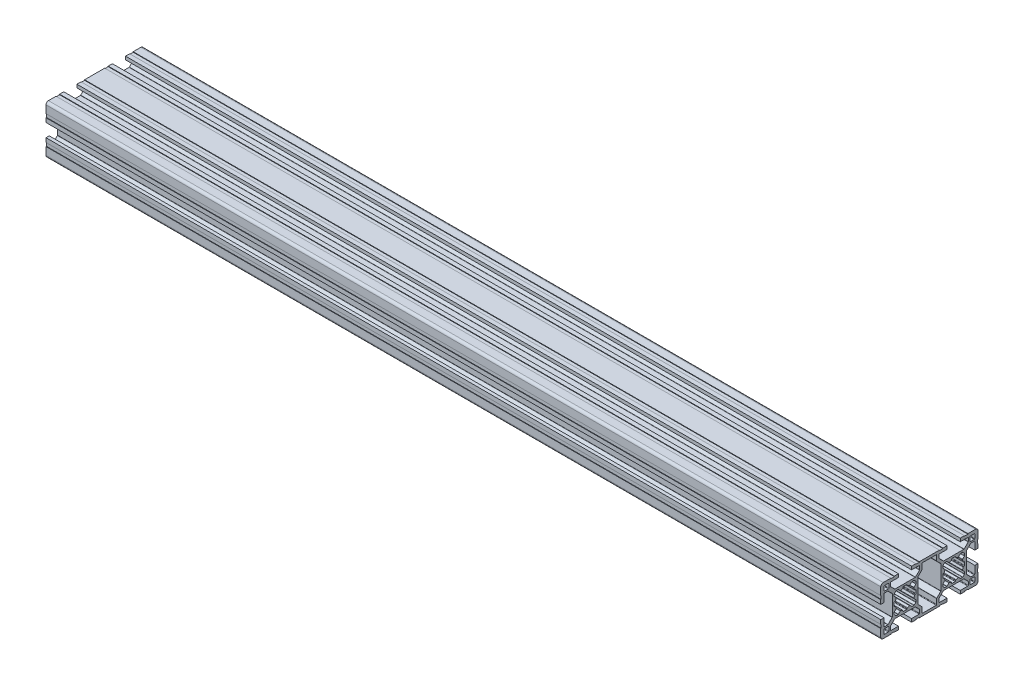
from build123d import *

# Parameters (mm, degrees)
RETANGULAR_PF30_02_PERFIL_3060_B_SICO_DEPTH = 515


with BuildPart() as part:
    # Sketch11 → Retangular PF30-02 - PERFIL 3060 BÁSICO(1) (new body)
    with BuildSketch(Plane.YZ.offset(-257.5)):
        with BuildLine():
            Line((-10.467761979, 23.914900409), (-7.987862303, 21.435000909))
            ThreePointArc((-7.987862303, 21.435000909), (-7.922830472, 21.337673902), (-7.89999433, 21.222868867))
            Line((-7.89999433, 21.222868867), (-7.89999433, 8.78267257))
            ThreePointArc((-7.89999433, 8.78267257), (-7.922830472, 8.667867535), (-7.987862303, 8.570540528))
            Line((-7.987862303, 8.570540528), (-10.467761979, 6.090641028))
            ThreePointArc((-10.467761979, 6.090641028), (-10.565088981, 6.025609208), (-10.679894006, 6.00277307))
            Line((-10.679894006, 6.00277307), (-12.699995366, 6.00277307))
            ThreePointArc((-12.699995366, 6.00277307), (-12.9121274, 6.090641035), (-12.999995366, 6.30277307))
            Line((-12.999995366, 6.30277307), (-12.999995366, 10.952772018))
            Line((-12.999995366, 10.952772018), (-14.999995923, 10.952772018))
            Line((-14.999995923, 10.952772018), (-14.999995923, 8.402773901))
            Line((-14.999995923, 8.402773901), (-14.699995922, 8.402773901))
            Line((-14.699995922, 8.402773901), (-14.699995922, 6.2027739))
            Line((-14.699995922, 6.2027739), (-14.999995923, 6.2027739))
            Line((-14.999995923, 6.2027739), (-14.999995923, -6.197224309))
            Line((-14.999995923, -6.197224309), (-14.699995922, -6.197224309))
            Line((-14.699995922, -6.197224309), (-14.699995922, -8.397224309))
            Line((-14.699995922, -8.397224309), (-14.999995923, -8.397224309))
            Line((-14.999995923, -8.397224309), (-14.999995923, -10.947222427))
            Line((-14.999995923, -10.947222427), (-12.999995366, -10.947222427))
            Line((-12.999995366, -10.947222427), (-12.999995366, -6.297223478))
            ThreePointArc((-12.999995366, -6.297223478), (-12.9121274, -6.085091444), (-12.699995366, -5.997223478))
            Line((-12.699995366, -5.997223478), (-10.679894006, -5.997223478))
            ThreePointArc((-10.679894006, -5.997223478), (-10.565088981, -6.020059616), (-10.467761979, -6.085091436))
            Line((-10.467761979, -6.085091436), (-7.987862303, -8.564990936))
            ThreePointArc((-7.987862303, -8.564990936), (-7.922830472, -8.662317943), (-7.89999433, -8.777122978))
            Line((-7.89999433, -8.777122978), (-7.89999433, -21.217319276))
            ThreePointArc((-7.89999433, -21.217319276), (-7.922830472, -21.33212431), (-7.987862303, -21.429451318))
            Line((-7.987862303, -21.429451318), (-10.467761979, -23.909350818))
            ThreePointArc((-10.467761979, -23.909350818), (-10.565088981, -23.974382637), (-10.679894006, -23.997218776))
            Line((-10.679894006, -23.997218776), (-12.699995366, -23.997218776))
            ThreePointArc((-12.699995366, -23.997218776), (-12.9121274, -23.90935081), (-12.999995366, -23.697218776))
            Line((-12.999995366, -23.697218776), (-12.999995366, -19.047219827))
            Line((-12.999995366, -19.047219827), (-14.999995923, -19.047219827))
            Line((-14.999995923, -19.047219827), (-14.999995923, -21.597217945))
            Line((-14.999995923, -21.597217945), (-14.699995922, -21.597217945))
            Line((-14.699995922, -21.597217945), (-14.699995922, -23.797217945))
            Line((-14.699995922, -23.797217945), (-14.999995923, -23.797217945))
            Line((-14.999995923, -23.797217945), (-14.999995923, -28.497216952))
            ThreePointArc((-14.999995923, -28.497216952), (-14.560656066, -29.557877193), (-13.499995825, -29.997217049))
            Line((-13.499995825, -29.997217049), (-8.799996802, -29.997217049))
            Line((-8.799996802, -29.997217049), (-8.799996802, -29.697217049))
            Line((-8.799996802, -29.697217049), (-6.599996802, -29.697217049))
            Line((-6.599996802, -29.697217049), (-6.599996802, -29.99721705))
            Line((-6.599996802, -29.99721705), (-4.0499987, -29.99721705))
            Line((-4.0499987, -29.99721705), (-4.0499987, -27.997216493))
            Line((-4.0499987, -27.997216493), (-8.699997649, -27.997216493))
            ThreePointArc((-8.699997649, -27.997216493), (-8.912129683, -27.909348527), (-8.999997649, -27.697216493))
            Line((-8.999997649, -27.697216493), (-8.999997649, -25.677115133))
            ThreePointArc((-8.999997649, -25.677115133), (-8.977161511, -25.562310108), (-8.912129691, -25.464983106))
            Line((-8.912129691, -25.464983106), (-6.432230191, -22.98508343))
            ThreePointArc((-6.432230191, -22.98508343), (-6.334903184, -22.920051599), (-6.220098149, -22.897215457))
            Line((-6.220098149, -22.897215457), (6.220098149, -22.897215457))
            ThreePointArc((6.220098149, -22.897215457), (6.334903184, -22.920051599), (6.432230191, -22.98508343))
            Line((6.432230191, -22.98508343), (8.912129691, -25.464983106))
            ThreePointArc((8.912129691, -25.464983106), (8.977161511, -25.562310108), (8.999997649, -25.677115133))
            Line((8.999997649, -25.677115133), (8.999997649, -27.697216493))
            ThreePointArc((8.999997649, -27.697216493), (8.912129683, -27.909348527), (8.699997649, -27.997216493))
            Line((8.699997649, -27.997216493), (4.0499987, -27.997216493))
            Line((4.0499987, -27.997216493), (4.0499987, -29.99721705))
            Line((4.0499987, -29.99721705), (6.599996802, -29.99721705))
            Line((6.599996802, -29.99721705), (6.599996802, -29.697217049))
            Line((6.599996802, -29.697217049), (8.799996802, -29.697217049))
            Line((8.799996802, -29.697217049), (8.799996802, -29.997217049))
            Line((8.799996802, -29.997217049), (13.499995825, -29.997217049))
            ThreePointArc((13.499995825, -29.997217049), (14.560656066, -29.557877193), (14.999995923, -28.497216952))
            Line((14.999995923, -28.497216952), (14.999995923, -23.797217945))
            Line((14.999995923, -23.797217945), (14.699995922, -23.797217945))
            Line((14.699995922, -23.797217945), (14.699995922, -21.597217945))
            Line((14.699995922, -21.597217945), (14.999995923, -21.597217945))
            Line((14.999995923, -21.597217945), (14.999995923, -19.047219827))
            Line((14.999995923, -19.047219827), (12.999995366, -19.047219827))
            Line((12.999995366, -19.047219827), (12.999995366, -23.697218776))
            ThreePointArc((12.999995366, -23.697218776), (12.9121274, -23.90935081), (12.699995366, -23.997218776))
            Line((12.699995366, -23.997218776), (10.679894006, -23.997218776))
            ThreePointArc((10.679894006, -23.997218776), (10.565088981, -23.974382637), (10.467761979, -23.909350818))
            Line((10.467761979, -23.909350818), (7.987862303, -21.429451318))
            ThreePointArc((7.987862303, -21.429451318), (7.922830472, -21.33212431), (7.89999433, -21.217319276))
            Line((7.89999433, -21.217319276), (7.89999433, -8.777122978))
            ThreePointArc((7.89999433, -8.777122978), (7.922830472, -8.662317943), (7.987862303, -8.564990936))
            Line((7.987862303, -8.564990936), (10.467761979, -6.085091436))
            ThreePointArc((10.467761979, -6.085091436), (10.565088981, -6.020059616), (10.679894006, -5.997223478))
            Line((10.679894006, -5.997223478), (12.699995366, -5.997223478))
            ThreePointArc((12.699995366, -5.997223478), (12.9121274, -6.085091444), (12.999995366, -6.297223478))
            Line((12.999995366, -6.297223478), (12.999995366, -10.947222427))
            Line((12.999995366, -10.947222427), (14.999995923, -10.947222427))
            Line((14.999995923, -10.947222427), (14.999995923, -8.397224309))
            Line((14.999995923, -8.397224309), (14.699995922, -8.397224309))
            Line((14.699995922, -8.397224309), (14.699995922, -6.197224309))
            Line((14.699995922, -6.197224309), (14.999995923, -6.197224309))
            Line((14.999995923, -6.197224309), (14.999995923, 6.2027739))
            Line((14.999995923, 6.2027739), (14.699995922, 6.2027739))
            Line((14.699995922, 6.2027739), (14.699995922, 8.402773901))
            Line((14.699995922, 8.402773901), (14.999995923, 8.402773901))
            Line((14.999995923, 8.402773901), (14.999995923, 10.952772018))
            Line((14.999995923, 10.952772018), (12.999995366, 10.952772018))
            Line((12.999995366, 10.952772018), (12.999995366, 6.30277307))
            ThreePointArc((12.999995366, 6.30277307), (12.9121274, 6.090641035), (12.699995366, 6.00277307))
            Line((12.699995366, 6.00277307), (10.679894006, 6.00277307))
            ThreePointArc((10.679894006, 6.00277307), (10.565088981, 6.025609208), (10.467761979, 6.090641028))
            Line((10.467761979, 6.090641028), (7.987862303, 8.570540528))
            ThreePointArc((7.987862303, 8.570540528), (7.922830472, 8.667867535), (7.89999433, 8.78267257))
            Line((7.89999433, 8.78267257), (7.89999433, 21.222868867))
            ThreePointArc((7.89999433, 21.222868867), (7.922830472, 21.337673902), (7.987862303, 21.435000909))
            Line((7.987862303, 21.435000909), (10.467761979, 23.914900409))
            ThreePointArc((10.467761979, 23.914900409), (10.565088981, 23.979932229), (10.679894006, 24.002768367))
            Line((10.679894006, 24.002768367), (12.699995366, 24.002768367))
            ThreePointArc((12.699995366, 24.002768367), (12.9121274, 23.914900401), (12.999995366, 23.702768367))
            Line((12.999995366, 23.702768367), (12.999995366, 19.052769418))
            Line((12.999995366, 19.052769418), (14.999995923, 19.052769418))
            Line((14.999995923, 19.052769418), (14.999995923, 21.602767536))
            Line((14.999995923, 21.602767536), (14.699995922, 21.602767536))
            Line((14.699995922, 21.602767536), (14.699995922, 23.802767536))
            Line((14.699995922, 23.802767536), (14.999995923, 23.802767536))
            Line((14.999995923, 23.802767536), (14.999995923, 28.502766544))
            ThreePointArc((14.999995923, 28.502766544), (14.560656066, 29.563426784), (13.499995825, 30.002766641))
            Line((13.499995825, 30.002766641), (8.799996802, 30.002766641))
            Line((8.799996802, 30.002766641), (8.799996802, 29.702766641))
            Line((8.799996802, 29.702766641), (6.599996802, 29.702766641))
            Line((6.599996802, 29.702766641), (6.599996802, 30.002766641))
            Line((6.599996802, 30.002766641), (4.0499987, 30.002766641))
            Line((4.0499987, 30.002766641), (4.0499987, 28.002766084))
            Line((4.0499987, 28.002766084), (8.699997649, 28.002766084))
            ThreePointArc((8.699997649, 28.002766084), (8.912129683, 27.914898119), (8.999997649, 27.702766084))
            Line((8.999997649, 27.702766084), (8.999997649, 25.682664725))
            ThreePointArc((8.999997649, 25.682664725), (8.977161511, 25.5678597), (8.912129691, 25.470532698))
            Line((8.912129691, 25.470532698), (6.432230191, 22.990633021))
            ThreePointArc((6.432230191, 22.990633021), (6.334903184, 22.92560119), (6.220098149, 22.902765048))
            Line((6.220098149, 22.902765048), (-6.220098149, 22.902765048))
            ThreePointArc((-6.220098149, 22.902765048), (-6.334903184, 22.92560119), (-6.432230191, 22.990633021))
            Line((-6.432230191, 22.990633021), (-8.912129691, 25.470532698))
            ThreePointArc((-8.912129691, 25.470532698), (-8.977161511, 25.5678597), (-8.999997649, 25.682664725))
            Line((-8.999997649, 25.682664725), (-8.999997649, 27.702766084))
            ThreePointArc((-8.999997649, 27.702766084), (-8.912129683, 27.914898119), (-8.699997649, 28.002766084))
            Line((-8.699997649, 28.002766084), (-4.0499987, 28.002766084))
            Line((-4.0499987, 28.002766084), (-4.0499987, 30.002766641))
            Line((-4.0499987, 30.002766641), (-6.599996802, 30.002766641))
            Line((-6.599996802, 30.002766641), (-6.599996802, 29.702766641))
            Line((-6.599996802, 29.702766641), (-8.799996802, 29.702766641))
            Line((-8.799996802, 29.702766641), (-8.799996802, 30.002766641))
            Line((-8.799996802, 30.002766641), (-13.499995825, 30.002766641))
            ThreePointArc((-13.499995825, 30.002766641), (-14.560656066, 29.563426784), (-14.999995923, 28.502766544))
            Line((-14.999995923, 28.502766544), (-14.999995923, 23.802767536))
            Line((-14.999995923, 23.802767536), (-14.699995922, 23.802767536))
            Line((-14.699995922, 23.802767536), (-14.699995922, 21.602767536))
            Line((-14.699995922, 21.602767536), (-14.999995923, 21.602767536))
            Line((-14.999995923, 21.602767536), (-14.999995923, 19.052769418))
            Line((-14.999995923, 19.052769418), (-12.999995366, 19.052769418))
            Line((-12.999995366, 19.052769418), (-12.999995366, 23.702768367))
            ThreePointArc((-12.999995366, 23.702768367), (-12.9121274, 23.914900401), (-12.699995366, 24.002768367))
            Line((-12.699995366, 24.002768367), (-10.679894006, 24.002768367))
            ThreePointArc((-10.679894006, 24.002768367), (-10.565088981, 23.979932229), (-10.467761979, 23.914900409))
        make_face()
        with BuildLine():
            Line((-9.846446918, -4.590642769), (-7.422182, -7.014907859))
            ThreePointArc((-7.422182, -7.014907859), (-7.324854993, -7.07993969), (-7.210049959, -7.102775832))
            Line((-7.210049959, -7.102775832), (7.210049959, -7.102775832))
            ThreePointArc((7.210049959, -7.102775832), (7.324854993, -7.07993969), (7.422182, -7.014907859))
            Line((7.422182, -7.014907859), (9.846446918, -4.590642769))
            ThreePointArc((9.846446918, -4.590642769), (9.943773925, -4.525610938), (10.05857896, -4.502774796))
            Line((10.05857896, -4.502774796), (13.2, -4.502774796))
            ThreePointArc((13.2, -4.502774796), (13.412132034, -4.41490683), (13.5, -4.202774796))
            Line((13.5, -4.202774796), (13.5, 4.197225204))
            ThreePointArc((13.5, 4.197225204), (13.412132034, 4.409357239), (13.2, 4.497225204))
            Line((13.2, 4.497225204), (10.05857896, 4.497225204))
            ThreePointArc((10.05857896, 4.497225204), (9.943773925, 4.520061347), (9.846446918, 4.585093178))
            Line((9.846446918, 4.585093178), (7.422182001, 7.009358267))
            ThreePointArc((7.422182001, 7.009358267), (7.324854993, 7.074390098), (7.210049959, 7.097226241))
            Line((7.210049959, 7.097226241), (-7.210049958, 7.097226241))
            ThreePointArc((-7.210049958, 7.097226241), (-7.324854993, 7.074390098), (-7.422182, 7.009358267))
            Line((-7.422182, 7.009358267), (-9.846446917, 4.585093178))
            ThreePointArc((-9.846446917, 4.585093178), (-9.943773925, 4.520061347), (-10.058578959, 4.497225204))
            Line((-10.058578959, 4.497225204), (-13.2, 4.497225204))
            ThreePointArc((-13.2, 4.497225204), (-13.412132034, 4.409357239), (-13.5, 4.197225204))
            Line((-13.5, 4.197225204), (-13.5, -4.202774796))
            ThreePointArc((-13.5, -4.202774796), (-13.412132034, -4.41490683), (-13.2, -4.502774796))
            Line((-13.2, -4.502774796), (-10.05857896, -4.502774796))
            ThreePointArc((-10.05857896, -4.502774796), (-9.943773925, -4.525610938), (-9.846446918, -4.590642769))
        make_face(mode=Mode.SUBTRACT)
        with BuildLine():
            Line((-6.69999433, 15.952769357), (-6.69999433, 14.05277208))
            ThreePointArc((-6.69999433, 14.05277208), (-6.612125883, 13.840639564), (-6.399992969, 13.75277208))
            Line((-6.399992969, 13.75277208), (-6.157923707, 13.752773178))
            ThreePointArc((-6.157923707, 13.752773178), (-5.973489249, 13.689383475), (-5.866996881, 13.526001408))
            ThreePointArc((-5.866996881, 13.526001408), (-5.679815238, 12.918976375), (-5.430017698, 12.334923683))
            ThreePointArc((-5.430017698, 12.334923683), (-5.403317864, 12.15354701), (-5.487142739, 11.990501713))
            Line((-5.487142739, 11.990501713), (-6.612126364, 10.865518089))
            ThreePointArc((-6.612126364, 10.865518089), (-6.677158189, 10.768191084), (-6.69999433, 10.653386054))
            Line((-6.69999433, 10.653386054), (-6.69999433, 9.563210784))
            ThreePointArc((-6.69999433, 9.563210784), (-6.677158176, 9.448405723), (-6.612126315, 9.351078701))
            Line((-6.612126315, 9.351078701), (-6.131909052, 8.870861658))
            Line((-6.131909052, 8.870861658), (-5.651692017, 8.390644403))
            ThreePointArc((-5.651692017, 8.390644403), (-5.554364996, 8.325612542), (-5.439559934, 8.302776389))
            Line((-5.439559934, 8.302776389), (-4.349384664, 8.302776389))
            ThreePointArc((-4.349384664, 8.302776389), (-4.234579634, 8.325612529), (-4.13725263, 8.390644354))
            Line((-4.13725263, 8.390644354), (-3.012269005, 9.515627979))
            ThreePointArc((-3.012269005, 9.515627979), (-2.849223708, 9.599452854), (-2.667847035, 9.572753021))
            ThreePointArc((-2.667847035, 9.572753021), (-2.083794343, 9.322955481), (-1.476769311, 9.135773837))
            ThreePointArc((-1.476769311, 9.135773837), (-1.313387244, 9.02928147), (-1.249997541, 8.844847011))
            Line((-1.249997541, 8.844847011), (-1.249998639, 8.60277775))
            ThreePointArc((-1.249998639, 8.60277775), (-1.162131155, 8.390644836), (-0.949998639, 8.302776389))
            Line((-0.949998639, 8.302776389), (0.949998639, 8.302776389))
            ThreePointArc((0.949998639, 8.302776389), (1.162131155, 8.390644836), (1.249998639, 8.60277775))
            Line((1.249998639, 8.60277775), (1.249997541, 8.844847011))
            ThreePointArc((1.249997541, 8.844847011), (1.313387244, 9.02928147), (1.476769311, 9.135773837))
            ThreePointArc((1.476769311, 9.135773837), (2.083794343, 9.322955481), (2.667847035, 9.572753021))
            ThreePointArc((2.667847035, 9.572753021), (2.849223708, 9.599452854), (3.012269005, 9.515627979))
            Line((3.012269005, 9.515627979), (4.13725263, 8.390644354))
            ThreePointArc((4.13725263, 8.390644354), (4.234579634, 8.325612529), (4.349384664, 8.302776389))
            Line((4.349384664, 8.302776389), (5.439559934, 8.302776389))
            ThreePointArc((5.439559934, 8.302776389), (5.554364996, 8.325612542), (5.651692017, 8.390644403))
            Line((5.651692017, 8.390644403), (6.131909052, 8.870861658))
            Line((6.131909052, 8.870861658), (6.612126315, 9.351078701))
            ThreePointArc((6.612126315, 9.351078701), (6.677158176, 9.448405723), (6.69999433, 9.563210784))
            Line((6.69999433, 9.563210784), (6.69999433, 10.653386054))
            ThreePointArc((6.69999433, 10.653386054), (6.677158189, 10.768191084), (6.612126364, 10.865518089))
            Line((6.612126364, 10.865518089), (5.487142739, 11.990501713))
            ThreePointArc((5.487142739, 11.990501713), (5.403317864, 12.15354701), (5.430017698, 12.334923683))
            ThreePointArc((5.430017698, 12.334923683), (5.679815238, 12.918976375), (5.866996881, 13.526001408))
            ThreePointArc((5.866996881, 13.526001408), (5.973489249, 13.689383475), (6.157923707, 13.752773178))
            Line((6.157923707, 13.752773178), (6.399992969, 13.75277208))
            ThreePointArc((6.399992969, 13.75277208), (6.612125883, 13.840639564), (6.69999433, 14.05277208))
            Line((6.69999433, 14.05277208), (6.69999433, 15.952769357))
            ThreePointArc((6.69999433, 15.952769357), (6.612125883, 16.164901872), (6.399992969, 16.252769357))
            Line((6.399992969, 16.252769357), (6.157923707, 16.252768259))
            ThreePointArc((6.157923707, 16.252768259), (5.973489249, 16.316157962), (5.866996881, 16.479540029))
            ThreePointArc((5.866996881, 16.479540029), (5.679815238, 17.086565061), (5.430017698, 17.670617753))
            ThreePointArc((5.430017698, 17.670617753), (5.403317864, 17.851994426), (5.487142739, 18.015039723))
            Line((5.487142739, 18.015039723), (6.612126364, 19.140023348))
            ThreePointArc((6.612126364, 19.140023348), (6.677158189, 19.237350353), (6.69999433, 19.352155382))
            Line((6.69999433, 19.352155382), (6.69999433, 20.442330653))
            ThreePointArc((6.69999433, 20.442330653), (6.677158176, 20.557135714), (6.612126315, 20.654462736))
            Line((6.612126315, 20.654462736), (6.131909052, 21.134679779))
            Line((6.131909052, 21.134679779), (5.651692017, 21.614897034))
            ThreePointArc((5.651692017, 21.614897034), (5.554364996, 21.679928895), (5.439559934, 21.702765048))
            Line((5.439559934, 21.702765048), (4.349384664, 21.702765048))
            ThreePointArc((4.349384664, 21.702765048), (4.234579634, 21.679928908), (4.13725263, 21.614897082))
            Line((4.13725263, 21.614897082), (3.012269005, 20.489913458))
            ThreePointArc((3.012269005, 20.489913458), (2.849223708, 20.406088583), (2.667847035, 20.432788416))
            ThreePointArc((2.667847035, 20.432788416), (2.083794343, 20.682585956), (1.476769311, 20.869767599))
            ThreePointArc((1.476769311, 20.869767599), (1.313387244, 20.976259967), (1.249997541, 21.160694426))
            Line((1.249997541, 21.160694426), (1.249998639, 21.402763687))
            ThreePointArc((1.249998639, 21.402763687), (1.162131155, 21.614896601), (0.949998639, 21.702765048))
            Line((0.949998639, 21.702765048), (-0.949998639, 21.702765048))
            ThreePointArc((-0.949998639, 21.702765048), (-1.162131155, 21.614896601), (-1.249998639, 21.402763687))
            Line((-1.249998639, 21.402763687), (-1.249997541, 21.160694426))
            ThreePointArc((-1.249997541, 21.160694426), (-1.313387244, 20.976259967), (-1.476769311, 20.869767599))
            ThreePointArc((-1.476769311, 20.869767599), (-2.083794343, 20.682585956), (-2.667847035, 20.432788416))
            ThreePointArc((-2.667847035, 20.432788416), (-2.849223708, 20.406088583), (-3.012269005, 20.489913458))
            Line((-3.012269005, 20.489913458), (-4.13725263, 21.614897082))
            ThreePointArc((-4.13725263, 21.614897082), (-4.234579634, 21.679928908), (-4.349384664, 21.702765048))
            Line((-4.349384664, 21.702765048), (-5.439559934, 21.702765048))
            ThreePointArc((-5.439559934, 21.702765048), (-5.554364996, 21.679928895), (-5.651692017, 21.614897034))
            Line((-5.651692017, 21.614897034), (-6.131909052, 21.134679779))
            Line((-6.131909052, 21.134679779), (-6.612126315, 20.654462736))
            ThreePointArc((-6.612126315, 20.654462736), (-6.677158176, 20.557135714), (-6.69999433, 20.442330653))
            Line((-6.69999433, 20.442330653), (-6.69999433, 19.352155382))
            ThreePointArc((-6.69999433, 19.352155382), (-6.677158189, 19.237350353), (-6.612126364, 19.140023348))
            Line((-6.612126364, 19.140023348), (-5.487142739, 18.015039723))
            ThreePointArc((-5.487142739, 18.015039723), (-5.403317864, 17.851994426), (-5.430017698, 17.670617753))
            ThreePointArc((-5.430017698, 17.670617753), (-5.679815238, 17.086565061), (-5.866996881, 16.479540029))
            ThreePointArc((-5.866996881, 16.479540029), (-5.973489249, 16.316157962), (-6.157923707, 16.252768259))
            Line((-6.157923707, 16.252768259), (-6.399992969, 16.252769357))
            ThreePointArc((-6.399992969, 16.252769357), (-6.612125883, 16.164901872), (-6.69999433, 15.952769357))
        make_face(mode=Mode.SUBTRACT)
        with BuildLine():
            Line((-12.999997649, 25.302766084), (-12.999997649, 27.702766084))
            ThreePointArc((-12.999997649, 27.702766084), (-12.912129683, 27.914898119), (-12.699997649, 28.002766084))
            Line((-12.699997649, 28.002766084), (-10.299997649, 28.002766084))
            ThreePointArc((-10.299997649, 28.002766084), (-10.087865615, 27.914898119), (-9.999997649, 27.702766084))
            Line((-9.999997649, 27.702766084), (-9.999997649, 25.302766084))
            ThreePointArc((-9.999997649, 25.302766084), (-10.087865615, 25.09063405), (-10.299997649, 25.002766084))
            Line((-10.299997649, 25.002766084), (-12.699997649, 25.002766084))
            ThreePointArc((-12.699997649, 25.002766084), (-12.912129683, 25.09063405), (-12.999997649, 25.302766084))
        make_face(mode=Mode.SUBTRACT)
        with BuildLine():
            Line((10.299997649, 25.002766084), (12.699997649, 25.002766084))
            ThreePointArc((12.699997649, 25.002766084), (12.912129683, 25.09063405), (12.999997649, 25.302766084))
            Line((12.999997649, 25.302766084), (12.999997649, 27.702766084))
            ThreePointArc((12.999997649, 27.702766084), (12.912129683, 27.914898119), (12.699997649, 28.002766084))
            Line((12.699997649, 28.002766084), (10.299997649, 28.002766084))
            ThreePointArc((10.299997649, 28.002766084), (10.087865615, 27.914898119), (9.999997649, 27.702766084))
            Line((9.999997649, 27.702766084), (9.999997649, 25.302766084))
            ThreePointArc((9.999997649, 25.302766084), (10.087865615, 25.09063405), (10.299997649, 25.002766084))
        make_face(mode=Mode.SUBTRACT)
        with BuildLine():
            Line((-6.157923707, -13.747223586), (-6.399992969, -13.747222488))
            ThreePointArc((-6.399992969, -13.747222488), (-6.612125883, -13.835089973), (-6.69999433, -14.047222488))
            Line((-6.69999433, -14.047222488), (-6.69999433, -15.947219765))
            ThreePointArc((-6.69999433, -15.947219765), (-6.612125883, -16.159352281), (-6.399992969, -16.247219765))
            Line((-6.399992969, -16.247219765), (-6.157923707, -16.247218667))
            ThreePointArc((-6.157923707, -16.247218667), (-5.973489249, -16.310608371), (-5.866996881, -16.473990437))
            ThreePointArc((-5.866996881, -16.473990437), (-5.679815238, -17.08101547), (-5.430017698, -17.665068162))
            ThreePointArc((-5.430017698, -17.665068162), (-5.403317864, -17.846444835), (-5.487142739, -18.009490132))
            Line((-5.487142739, -18.009490132), (-6.612126364, -19.134473757))
            ThreePointArc((-6.612126364, -19.134473757), (-6.677158189, -19.231800761), (-6.69999433, -19.346605791))
            Line((-6.69999433, -19.346605791), (-6.69999433, -20.436781061))
            ThreePointArc((-6.69999433, -20.436781061), (-6.677158176, -20.551586123), (-6.612126315, -20.648913144))
            Line((-6.612126315, -20.648913144), (-6.131909052, -21.129130187))
            Line((-6.131909052, -21.129130187), (-5.651692017, -21.609347442))
            ThreePointArc((-5.651692017, -21.609347442), (-5.554364996, -21.674379303), (-5.439559934, -21.697215457))
            Line((-5.439559934, -21.697215457), (-4.349384664, -21.697215457))
            ThreePointArc((-4.349384664, -21.697215457), (-4.234579634, -21.674379316), (-4.13725263, -21.609347491))
            Line((-4.13725263, -21.609347491), (-3.012269005, -20.484363866))
            ThreePointArc((-3.012269005, -20.484363866), (-2.849223708, -20.400538991), (-2.667847035, -20.427238825))
            ThreePointArc((-2.667847035, -20.427238825), (-2.083794343, -20.677036365), (-1.476769311, -20.864218008))
            ThreePointArc((-1.476769311, -20.864218008), (-1.313387244, -20.970710376), (-1.249997541, -21.155144834))
            Line((-1.249997541, -21.155144834), (-1.249998639, -21.397214096))
            ThreePointArc((-1.249998639, -21.397214096), (-1.162131155, -21.60934701), (-0.949998639, -21.697215457))
            Line((-0.949998639, -21.697215457), (0.949998639, -21.697215457))
            ThreePointArc((0.949998639, -21.697215457), (1.162131155, -21.60934701), (1.249998639, -21.397214096))
            Line((1.249998639, -21.397214096), (1.249997541, -21.155144834))
            ThreePointArc((1.249997541, -21.155144834), (1.313387244, -20.970710376), (1.476769311, -20.864218008))
            ThreePointArc((1.476769311, -20.864218008), (2.083794343, -20.677036365), (2.667847035, -20.427238825))
            ThreePointArc((2.667847035, -20.427238825), (2.849223708, -20.400538991), (3.012269005, -20.484363866))
            Line((3.012269005, -20.484363866), (4.13725263, -21.609347491))
            ThreePointArc((4.13725263, -21.609347491), (4.234579634, -21.674379316), (4.349384664, -21.697215457))
            Line((4.349384664, -21.697215457), (5.439559934, -21.697215457))
            ThreePointArc((5.439559934, -21.697215457), (5.554364996, -21.674379303), (5.651692017, -21.609347442))
            Line((5.651692017, -21.609347442), (6.131909052, -21.129130187))
            Line((6.131909052, -21.129130187), (6.612126315, -20.648913144))
            ThreePointArc((6.612126315, -20.648913144), (6.677158176, -20.551586123), (6.69999433, -20.436781061))
            Line((6.69999433, -20.436781061), (6.69999433, -19.346605791))
            ThreePointArc((6.69999433, -19.346605791), (6.677158189, -19.231800761), (6.612126364, -19.134473757))
            Line((6.612126364, -19.134473757), (5.487142739, -18.009490132))
            ThreePointArc((5.487142739, -18.009490132), (5.403317864, -17.846444835), (5.430017698, -17.665068162))
            ThreePointArc((5.430017698, -17.665068162), (5.679815238, -17.08101547), (5.866996881, -16.473990437))
            ThreePointArc((5.866996881, -16.473990437), (5.973489249, -16.310608371), (6.157923707, -16.247218667))
            Line((6.157923707, -16.247218667), (6.399992969, -16.247219765))
            ThreePointArc((6.399992969, -16.247219765), (6.612125883, -16.159352281), (6.69999433, -15.947219765))
            Line((6.69999433, -15.947219765), (6.69999433, -14.047222488))
            ThreePointArc((6.69999433, -14.047222488), (6.612125883, -13.835089973), (6.399992969, -13.747222488))
            Line((6.399992969, -13.747222488), (6.157923707, -13.747223586))
            ThreePointArc((6.157923707, -13.747223586), (5.973489249, -13.683833883), (5.866996881, -13.520451817))
            ThreePointArc((5.866996881, -13.520451817), (5.679815238, -12.913426784), (5.430017698, -12.329374092))
            ThreePointArc((5.430017698, -12.329374092), (5.403317864, -12.147997419), (5.487142739, -11.984952122))
            Line((5.487142739, -11.984952122), (6.612126364, -10.859968497))
            ThreePointArc((6.612126364, -10.859968497), (6.677158189, -10.762641493), (6.69999433, -10.647836463))
            Line((6.69999433, -10.647836463), (6.69999433, -9.557661193))
            ThreePointArc((6.69999433, -9.557661193), (6.677158176, -9.442856131), (6.612126315, -9.34552911))
            Line((6.612126315, -9.34552911), (6.131909052, -8.865312067))
            Line((6.131909052, -8.865312067), (5.651692017, -8.385094811))
            ThreePointArc((5.651692017, -8.385094811), (5.554364996, -8.320062951), (5.439559934, -8.297226797))
            Line((5.439559934, -8.297226797), (4.349384664, -8.297226797))
            ThreePointArc((4.349384664, -8.297226797), (4.234579634, -8.320062937), (4.13725263, -8.385094763))
            Line((4.13725263, -8.385094763), (3.012269005, -9.510078388))
            ThreePointArc((3.012269005, -9.510078388), (2.849223708, -9.593903263), (2.667847035, -9.567203429))
            ThreePointArc((2.667847035, -9.567203429), (2.083794343, -9.317405889), (1.476769311, -9.130224246))
            ThreePointArc((1.476769311, -9.130224246), (1.313387244, -9.023731878), (1.249997541, -8.83929742))
            Line((1.249997541, -8.83929742), (1.249998639, -8.597228158))
            ThreePointArc((1.249998639, -8.597228158), (1.162131155, -8.385095244), (0.949998639, -8.297226797))
            Line((0.949998639, -8.297226797), (-0.949998639, -8.297226797))
            ThreePointArc((-0.949998639, -8.297226797), (-1.162131155, -8.385095244), (-1.249998639, -8.597228158))
            Line((-1.249998639, -8.597228158), (-1.249997541, -8.83929742))
            ThreePointArc((-1.249997541, -8.83929742), (-1.313387244, -9.023731878), (-1.476769311, -9.130224246))
            ThreePointArc((-1.476769311, -9.130224246), (-2.083794343, -9.317405889), (-2.667847035, -9.567203429))
            ThreePointArc((-2.667847035, -9.567203429), (-2.849223708, -9.593903263), (-3.012269005, -9.510078388))
            Line((-3.012269005, -9.510078388), (-4.13725263, -8.385094763))
            ThreePointArc((-4.13725263, -8.385094763), (-4.234579634, -8.320062937), (-4.349384664, -8.297226797))
            Line((-4.349384664, -8.297226797), (-5.439559934, -8.297226797))
            ThreePointArc((-5.439559934, -8.297226797), (-5.554364996, -8.320062951), (-5.651692017, -8.385094811))
            Line((-5.651692017, -8.385094811), (-6.131909052, -8.865312067))
            Line((-6.131909052, -8.865312067), (-6.612126315, -9.34552911))
            ThreePointArc((-6.612126315, -9.34552911), (-6.677158176, -9.442856131), (-6.69999433, -9.557661193))
            Line((-6.69999433, -9.557661193), (-6.69999433, -10.647836463))
            ThreePointArc((-6.69999433, -10.647836463), (-6.677158189, -10.762641493), (-6.612126364, -10.859968497))
            Line((-6.612126364, -10.859968497), (-5.487142739, -11.984952122))
            ThreePointArc((-5.487142739, -11.984952122), (-5.403317864, -12.147997419), (-5.430017698, -12.329374092))
            ThreePointArc((-5.430017698, -12.329374092), (-5.679815238, -12.913426784), (-5.866996881, -13.520451817))
            ThreePointArc((-5.866996881, -13.520451817), (-5.973489249, -13.683833883), (-6.157923707, -13.747223586))
        make_face(mode=Mode.SUBTRACT)
        with BuildLine():
            Line((-10.299997649, -24.997216493), (-12.699997649, -24.997216493))
            ThreePointArc((-12.699997649, -24.997216493), (-12.912129683, -25.085084458), (-12.999997649, -25.297216493))
            Line((-12.999997649, -25.297216493), (-12.999997649, -27.697216493))
            ThreePointArc((-12.999997649, -27.697216493), (-12.912129683, -27.909348527), (-12.699997649, -27.997216493))
            Line((-12.699997649, -27.997216493), (-10.299997649, -27.997216493))
            ThreePointArc((-10.299997649, -27.997216493), (-10.087865615, -27.909348527), (-9.999997649, -27.697216493))
            Line((-9.999997649, -27.697216493), (-9.999997649, -25.297216493))
            ThreePointArc((-9.999997649, -25.297216493), (-10.087865615, -25.085084458), (-10.299997649, -24.997216493))
        make_face(mode=Mode.SUBTRACT)
        with BuildLine():
            Line((12.999997649, -25.297216493), (12.999997649, -27.697216493))
            ThreePointArc((12.999997649, -27.697216493), (12.912129683, -27.909348527), (12.699997649, -27.997216493))
            Line((12.699997649, -27.997216493), (10.299997649, -27.997216493))
            ThreePointArc((10.299997649, -27.997216493), (10.087865615, -27.909348527), (9.999997649, -27.697216493))
            Line((9.999997649, -27.697216493), (9.999997649, -25.297216493))
            ThreePointArc((9.999997649, -25.297216493), (10.087865615, -25.085084458), (10.299997649, -24.997216493))
            Line((10.299997649, -24.997216493), (12.699997649, -24.997216493))
            ThreePointArc((12.699997649, -24.997216493), (12.912129683, -25.085084458), (12.999997649, -25.297216493))
        make_face(mode=Mode.SUBTRACT)
    extrude(amount=RETANGULAR_PF30_02_PERFIL_3060_B_SICO_DEPTH)


solid = part.part
